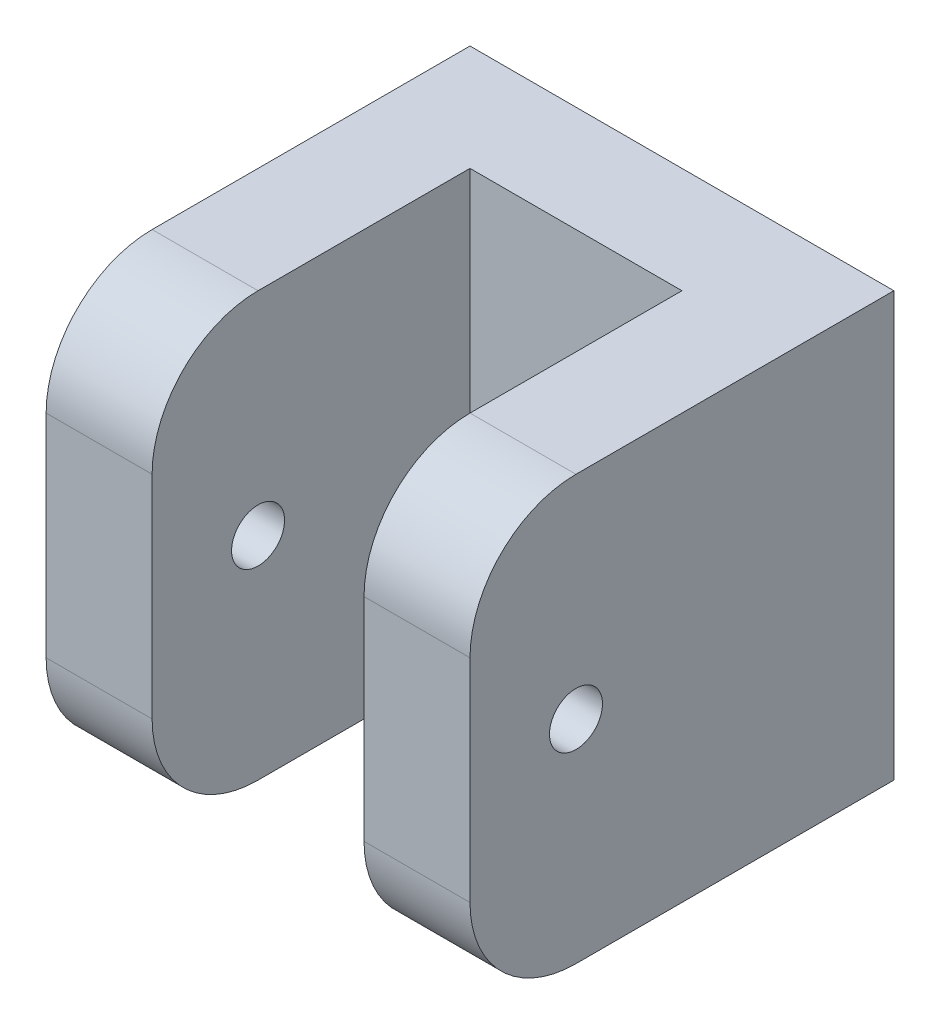
from build123d import *

# Parameters (mm, degrees)
SKETCH1_W           = 50.8
SKETCH1_H           = 50.8
BOSS_EXTRUDE1_DEPTH = 50.8
SKETCH2_W           = 25.4
SKETCH2_H           = 38.1
CUT_EXTRUDE1_DEPTH  = 51.8
SKETCH3_R           = 3.175
CUT_EXTRUDE2_DEPTH  = 13.7
SKETCH4_R           = 3.175
CUT_EXTRUDE3_DEPTH  = 51.8
FILLET1_R           = 12.7


with BuildPart() as part:
    # Sketch1 → Boss-Extrude1 (new body)
    with BuildSketch(Plane(origin=(0, 0, 0), x_dir=(1, 0, 0), z_dir=(0, 1, 0))):
        Rectangle(SKETCH1_W, SKETCH1_H)
    extrude(amount=BOSS_EXTRUDE1_DEPTH)

    # Sketch2 → Cut-Extrude1 (cut, through all)
    with BuildSketch(Plane(origin=(0, 50.8, 0), x_dir=(1, 0, 0), z_dir=(0, 1, 0))):
        with Locations((0, -6.35)):
            Rectangle(SKETCH2_W, SKETCH2_H)
    extrude(amount=-CUT_EXTRUDE1_DEPTH, mode=Mode.SUBTRACT)

    # Sketch3 → Cut-Extrude2 (cut, through all)
    with BuildSketch(Plane.XY.offset(-12.7)):
        with Locations((0, 25.4)):
            Circle(SKETCH3_R)
    extrude(amount=-CUT_EXTRUDE2_DEPTH, mode=Mode.SUBTRACT)

    # Sketch4 → Cut-Extrude3 (cut, through all)
    with BuildSketch(Plane(origin=(25.4, 0, 0), x_dir=(0, 0, -1), z_dir=(1, 0, 0))):
        with Locations((-12.7, 25.4)):
            Circle(SKETCH4_R)
    extrude(amount=-CUT_EXTRUDE3_DEPTH, mode=Mode.SUBTRACT)

    # Fillet1
    fillet1_edges = [part.edges().sort_by_distance(p)[0] for p in [
        (19.05, 0, 25.4),
        (19.05, 50.8, 25.4),
        (-19.05, 0, 25.4),
        (-19.05, 50.8, 25.4),
    ]]
    fillet(fillet1_edges, radius=FILLET1_R)


solid = part.part
